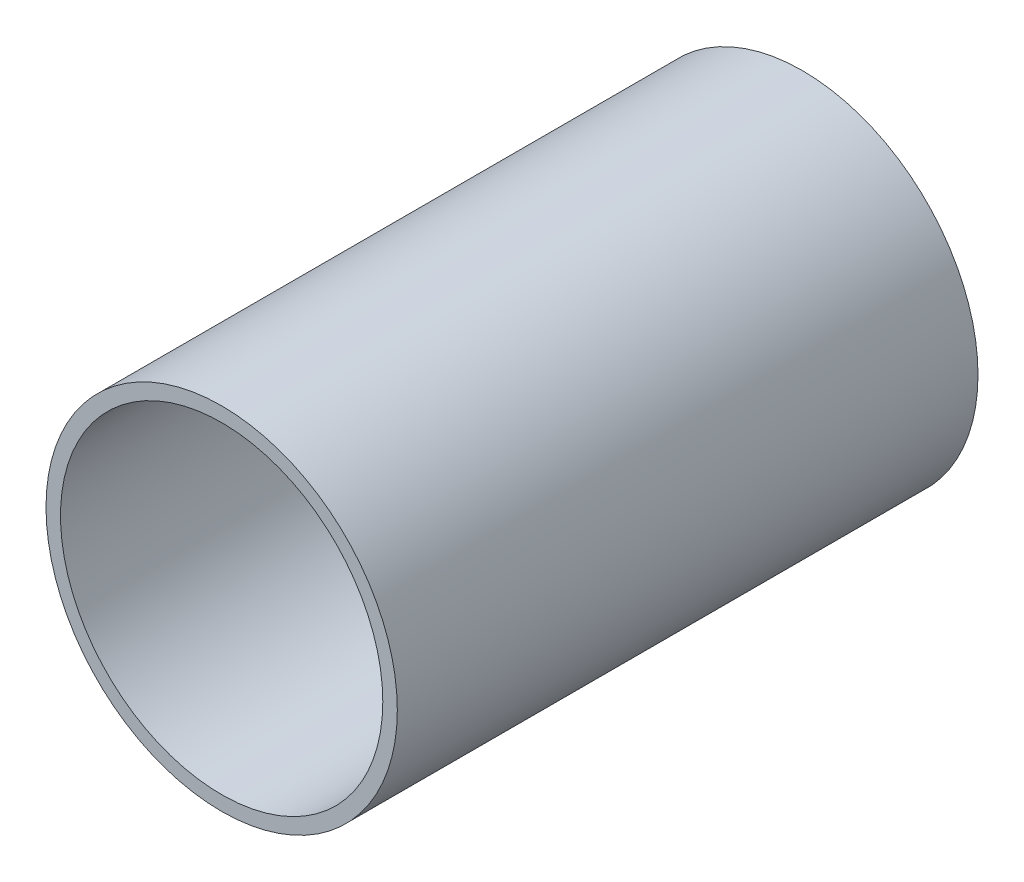
from build123d import *

# Parameters (mm, degrees)
SKETCH1_W = 200
SKETCH1_H = 5


with BuildPart() as part:
    # Sketch1 → Revolve1 (revolve)
    with BuildSketch(Plane(origin=(0, 0, 0), x_dir=(0, 0, -1), z_dir=(1, 0, 0))):
        with Locations((-21.407575419, 58)):
            Rectangle(SKETCH1_W, SKETCH1_H)
    revolve(axis=Axis((0, 0, 72.947664804), (0, 0, -1)))


solid = part.part
